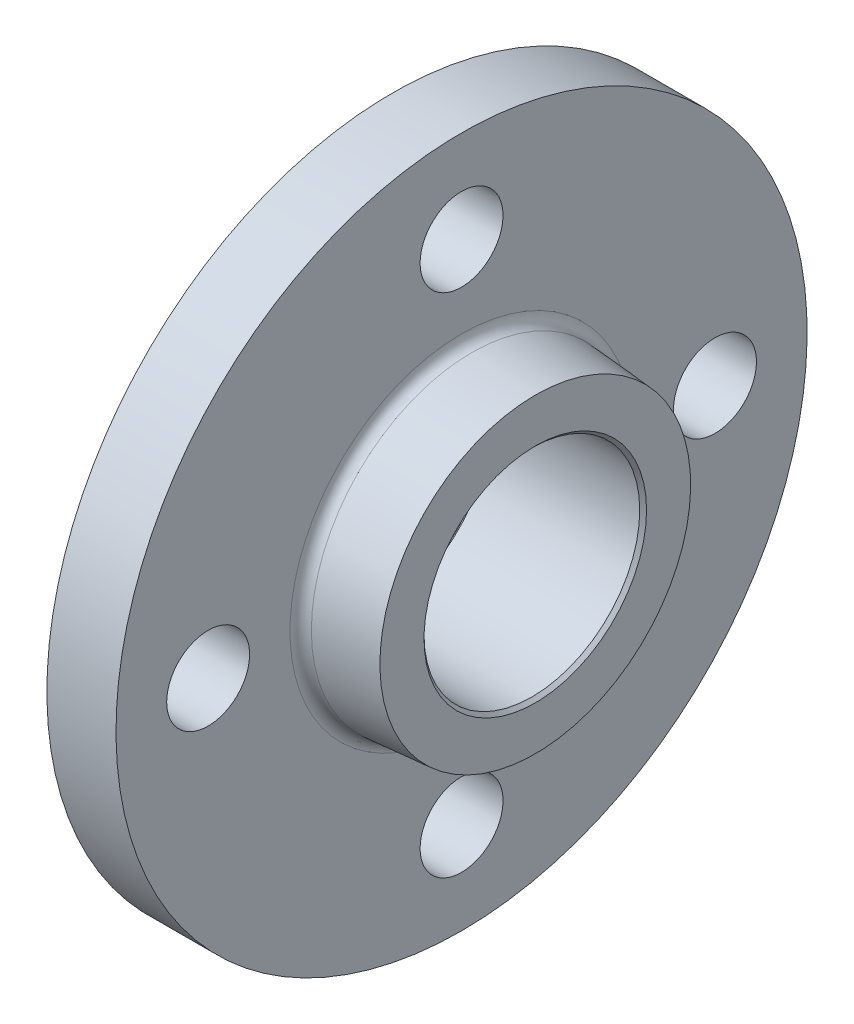
from build123d import *

# Parameters (mm, degrees)
SKETCH1_W                      = 15
SKETCH1_H                      = 75
SKETCH2_R                      = 44
BOSS_EXTRUDE1_DEPTH            = 3
SKETCH3_R                      = 35
BOSS_EXTRUDE2_DEPTH            = 16
BOSS_EXTRUDE2_TAPER            = 4.57392126
F_18_0_18_DIAMETER_HOLE1_D     = 18
F_18_0_18_DIAMETER_HOLE1_DEPTH = 31
M42_CLEARANCE_HOLE1_D          = 46.820907
M42_CLEARANCE_HOLE1_DEPTH      = 34
CHAMFER1_SIZE                  = 0.7395465
FILLET1_R                      = 2.415


with BuildPart() as part:
    # Sketch1 → Revolve1 (revolve)
    with BuildSketch(Plane(origin=(0, 0, 0), x_dir=(-1, 0, 0), z_dir=(0, 0, -1))):
        with Locations((-10.5, 37.5)):
            Rectangle(SKETCH1_W, SKETCH1_H)
    revolve(axis=Axis((18, 0, 0), (-1, 0, 0)))

    # Sketch2 → Boss-Extrude1 (add)
    with BuildSketch(Plane.ZY.offset(-3)):
        Circle(SKETCH2_R)
    extrude(amount=BOSS_EXTRUDE1_DEPTH)

    # Sketch3 → Boss-Extrude2 (add)
    with BuildSketch(Plane(origin=(18, 0, 0), x_dir=(0, 0, -1), z_dir=(1, 0, 0))):
        Circle(SKETCH3_R)
    extrude(amount=BOSS_EXTRUDE2_DEPTH, taper=BOSS_EXTRUDE2_TAPER)

    # Ø18.0 (18) Diameter Hole1
    with Locations(Plane.ZY.offset(-3)):
        with Locations((0, -55), (-55, 0), (0, 55), (55, 0)):
            Hole(F_18_0_18_DIAMETER_HOLE1_D / 2, depth=F_18_0_18_DIAMETER_HOLE1_DEPTH)

    # M42 Clearance Hole1
    with Locations(Plane(origin=(34, 0, 0), x_dir=(0, 0, -1), z_dir=(1, 0, 0))):
        with Locations((0, 0)):
            Hole(M42_CLEARANCE_HOLE1_D / 2, depth=M42_CLEARANCE_HOLE1_DEPTH)

    # Chamfer1
    chamfer1_edges = [part.edges().sort_by_distance(p)[0] for p in [
        (34, 0, -23.4104535),
        (0, 0, -23.4104535),
    ]]
    chamfer(chamfer1_edges, length=CHAMFER1_SIZE)

    # Fillet1
    fillet1_edges = [part.edges().sort_by_distance(p)[0] for p in [
        (18, 0, 35),
    ]]
    fillet(fillet1_edges, radius=FILLET1_R)


solid = part.part
